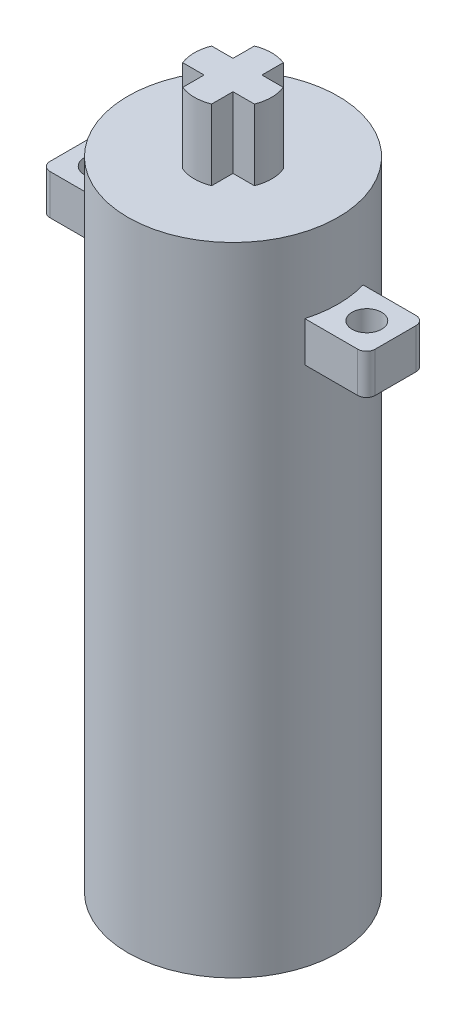
from build123d import *

# Parameters (mm, degrees)
VIGORSKETCH_R        = 0.8449945
VIGORFLANGE_DEPTH    = 2.2900005
VIGORAXLE_DEPTH      = 10.619994
VIGORSKETCH_8_R      = 6.0000007
VIGORBODY_DEPTH      = 6.579997
VIGORBODY_DEPTH_BACK = 29.78994804


with BuildPart() as part:
    # VigorSketch → VigorFlange (new body)
    with BuildSketch(Plane(origin=(0, 0, 0), x_dir=(1, 0, 0), z_dir=(0, 1, 0))):
        with BuildLine():
            ThreePointArc((-1.445618439, -1.6649954), (-2.2049994, 0), (-1.445618439, 1.6649954))
            Line((-1.445618439, 1.6649954), (-8.7849954, 1.6649954))
            ThreePointArc((-8.7849954, 1.6649954), (-9.138548791, 1.518548791), (-9.2849954, 1.1649954))
            Line((-9.2849954, 1.1649954), (-9.2849954, -1.1649954))
            ThreePointArc((-9.2849954, -1.1649954), (-9.138548791, -1.518548791), (-8.7849954, -1.6649954))
            Line((-8.7849954, -1.6649954), (-1.445618439, -1.6649954))
        make_face()
        with Locations((-7.64249678, 0)):
            Circle(VIGORSKETCH_R, mode=Mode.SUBTRACT)
        with BuildLine():
            ThreePointArc((1.445618439, 1.6649954), (2.2049994, 0), (1.445618439, -1.6649954))
            Line((1.445618439, -1.6649954), (8.7849954, -1.6649954))
            ThreePointArc((8.7849954, -1.6649954), (9.138548791, -1.518548791), (9.2849954, -1.1649954))
            Line((9.2849954, -1.1649954), (9.2849954, 1.1649954))
            ThreePointArc((9.2849954, 1.1649954), (9.138548791, 1.518548791), (8.7849954, 1.6649954))
            Line((8.7849954, 1.6649954), (1.445618439, 1.6649954))
        make_face()
        with Locations((7.64249678, 0)):
            Circle(VIGORSKETCH_R, mode=Mode.SUBTRACT)
    extrude(amount=VIGORFLANGE_DEPTH)

    # Sketch1_7 → VigorAxle (add)
    with BuildSketch(Plane(origin=(0, 0, 0), x_dir=(1, 0, 0), z_dir=(0, 1, 0))):
        with BuildLine():
            Line((0, 1.6649954), (0, -1.6649954))
            Line((0, -1.6649954), (0.824890579, -1.6649954))
            Line((0.824890579, -1.6649954), (0.824890579, -0.824890579))
            Line((0.824890579, -0.824890579), (2.044890679, -0.824890579))
            ThreePointArc((2.044890679, -0.824890579), (2.164602166, -0.420142615), (2.2049994, 0))
            ThreePointArc((2.2049994, 0), (2.164602166, 0.420142615), (2.044890679, 0.824890579))
            Line((2.044890679, 0.824890579), (0.824890579, 0.824890579))
            Line((0.824890579, 0.824890579), (0.824890579, 1.6649954))
            Line((0.824890579, 1.6649954), (0, 1.6649954))
        make_face()
        with BuildLine():
            Line((-0.824890579, -1.6649954), (0, -1.6649954))
            Line((0, -1.6649954), (0, 1.6649954))
            Line((0, 1.6649954), (-0.824890579, 1.6649954))
            Line((-0.824890579, 1.6649954), (-0.824890579, 0.824890579))
            Line((-0.824890579, 0.824890579), (-2.044890679, 0.824890579))
            ThreePointArc((-2.044890679, 0.824890579), (-2.2049994, 0), (-2.044890679, -0.824890579))
            Line((-2.044890679, -0.824890579), (-0.824890579, -0.824890579))
            Line((-0.824890579, -0.824890579), (-0.824890579, -1.6649954))
        make_face()
        with BuildLine():
            Line((-0.824890579, 1.6649954), (0, 1.6649954))
            Line((0, 1.6649954), (0.824890579, 1.6649954))
            Line((0.824890579, 1.6649954), (0.824890579, 2.044890679))
            ThreePointArc((0.824890579, 2.044890679), (0, 2.2049994), (-0.824890579, 2.044890679))
            Line((-0.824890579, 2.044890679), (-0.824890579, 1.6649954))
        make_face()
        with BuildLine():
            Line((0.824890579, -1.6649954), (0, -1.6649954))
            Line((0, -1.6649954), (-0.824890579, -1.6649954))
            Line((-0.824890579, -1.6649954), (-0.824890579, -2.044890679))
            ThreePointArc((-0.824890579, -2.044890679), (0, -2.2049994), (0.824890579, -2.044890679))
            Line((0.824890579, -2.044890679), (0.824890579, -1.6649954))
        make_face()
    extrude(amount=VIGORAXLE_DEPTH)

    # VigorSketch_8 → VigorBody (add, two sides)
    with BuildSketch(Plane(origin=(0, 0, 0), x_dir=(1, 0, 0), z_dir=(0, 1, 0))) as vigorbody_sk:
        Circle(VIGORSKETCH_8_R)
    extrude(amount=VIGORBODY_DEPTH)
    extrude(vigorbody_sk.sketch, amount=-VIGORBODY_DEPTH_BACK)


solid = part.part
